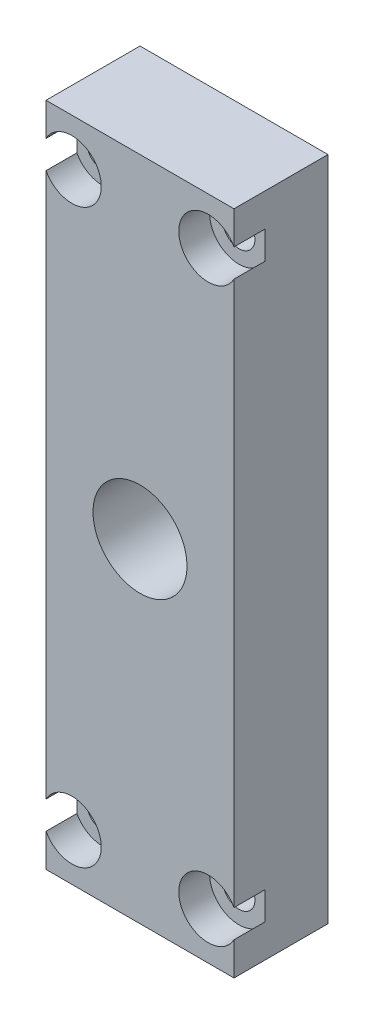
from build123d import *

# Parameters (mm, degrees)
SKETCH1_W                                      = 25.4
SKETCH1_H                                      = 12.7
BOSS_EXTRUDE1_DEPTH                            = 90.0176
CBORE_FOR_8_SOCKET_HEAD_CAP_SCREW1_D           = 4.3053
CBORE_FOR_8_SOCKET_HEAD_CAP_SCREW1_DEPTH       = 19.05
CBORE_FOR_8_SOCKET_HEAD_CAP_SCREW1_CBORE_D     = 7.9375
CBORE_FOR_8_SOCKET_HEAD_CAP_SCREW1_CBORE_DEPTH = 4.1656
CBORE_FOR_8_SOCKET_HEAD_CAP_SCREW1_TIP         = 1.293442612
F_1_2_0_5_DIAMETER_HOLE1_D                     = 12.7
F_1_2_0_5_DIAMETER_HOLE1_DEPTH                 = 15.24
F_1_2_0_5_DIAMETER_HOLE1_TIP                   = 3.815464931


with BuildPart() as part:
    # Sketch1 → Boss-Extrude1 (new body)
    with BuildSketch(Plane(origin=(0, 0, 0), x_dir=(1, 0, 0), z_dir=(0, 1, 0))):
        with Locations((12.7, 6.35)):
            Rectangle(SKETCH1_W, SKETCH1_H)
    extrude(amount=BOSS_EXTRUDE1_DEPTH)

    # CBORE for #8 Socket Head Cap Screw1
    with Locations(Plane(origin=(3.4925, 6.357975427, 0), x_dir=(1, 0, 0), z_dir=(0, 0, 1))):
        with Locations((0, 0), (18.415, 0), (18.415, 77.309624573), (0, 77.309624573)):
            CounterBoreHole(CBORE_FOR_8_SOCKET_HEAD_CAP_SCREW1_D / 2, CBORE_FOR_8_SOCKET_HEAD_CAP_SCREW1_CBORE_D / 2, CBORE_FOR_8_SOCKET_HEAD_CAP_SCREW1_CBORE_DEPTH, depth=CBORE_FOR_8_SOCKET_HEAD_CAP_SCREW1_DEPTH)
            with Locations((0, 0, -(CBORE_FOR_8_SOCKET_HEAD_CAP_SCREW1_DEPTH + CBORE_FOR_8_SOCKET_HEAD_CAP_SCREW1_TIP / 2))):  # 118° drill point
                Cone(0, CBORE_FOR_8_SOCKET_HEAD_CAP_SCREW1_D / 2, CBORE_FOR_8_SOCKET_HEAD_CAP_SCREW1_TIP, mode=Mode.SUBTRACT)

    # 1/2 (0.5) Diameter Hole1
    with Locations(Plane(origin=(12.7, 45.012787713, 0), x_dir=(1, 0, 0), z_dir=(0, 0, 1))):
        with Locations((0, 0)):
            Hole(F_1_2_0_5_DIAMETER_HOLE1_D / 2, depth=F_1_2_0_5_DIAMETER_HOLE1_DEPTH)
            with Locations((0, 0, -(F_1_2_0_5_DIAMETER_HOLE1_DEPTH + F_1_2_0_5_DIAMETER_HOLE1_TIP / 2))):  # 118° drill point
                Cone(0, F_1_2_0_5_DIAMETER_HOLE1_D / 2, F_1_2_0_5_DIAMETER_HOLE1_TIP, mode=Mode.SUBTRACT)


solid = part.part
